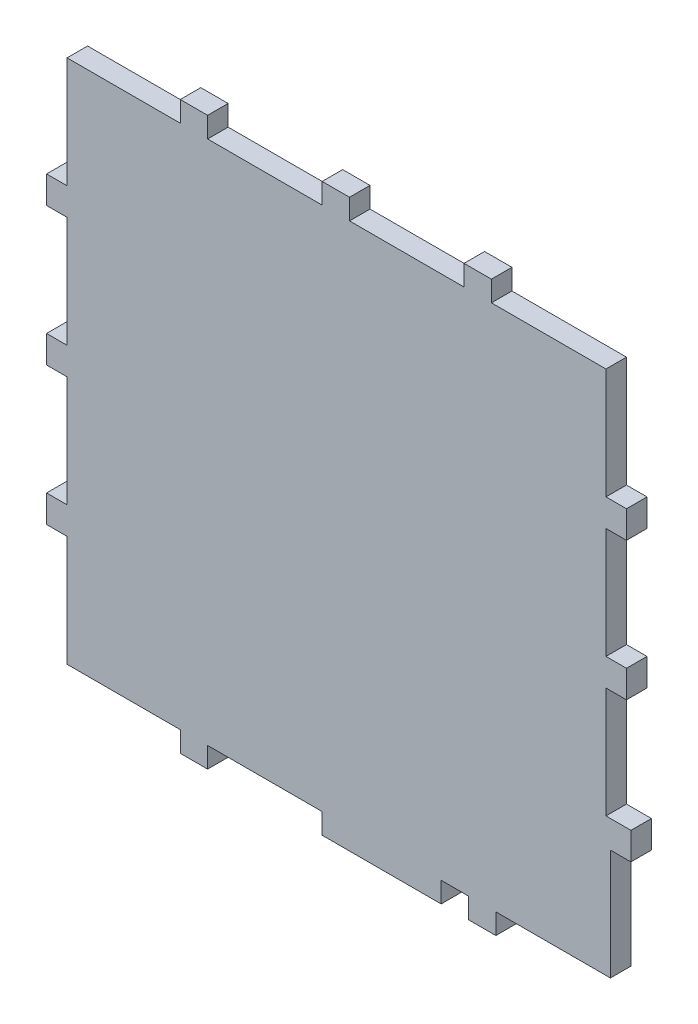
from build123d import *

# Parameters (mm, degrees)
BOSS_EXTRUDE1_DEPTH = 15


with BuildPart() as part:
    # Sketch1 → Boss-Extrude1 (new body)
    with BuildSketch(Plane.XY):
        Polygon((0, 0), (0, 81), (-15, 81), (-15, 101), (0, 101), (0, 182), (-15, 182), (-15, 202), (0, 202), (0, 283), (-15, 283), (-15, 303), (0, 303), (0, 384), (82.75, 384), (82.75, 399), (102.75, 399), (102.75, 384), (186.5, 384), (186.5, 399), (206.5, 399), (206.5, 384), (290.25, 384), (290.25, 399), (310.25, 399), (310.25, 384), (394, 384), (394, 303), (409, 303), (409, 283), (394, 283), (394, 202), (409, 202), (409, 182), (394, 182), (394, 101), (412.25, 101), (412.25, 81), (397.25, 81), (397.25, 0), (313.5, 0), (313.5, -15), (293.5, -15), (293.5, 0), (273.5, 0), (273.5, -15), (186.5, -15), (186.5, 0), (102.75, 0), (102.75, -15), (82.75, -15), (82.75, 0), align=None)
    extrude(amount=BOSS_EXTRUDE1_DEPTH)


solid = part.part
